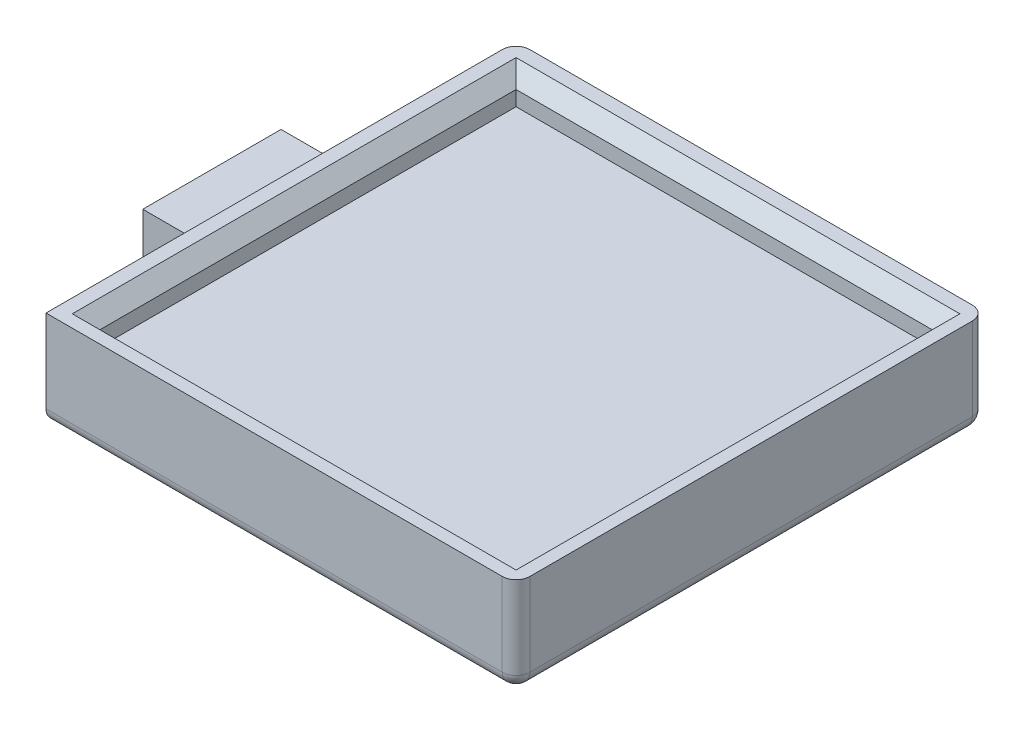
from build123d import *

# Parameters (mm, degrees)
EXTRUDE_1_DEPTH     = 5
SKETCH_2_W          = 34
SKETCH_2_H          = 34
EXTRUDE_2_DEPTH     = 2
SKETCH_3_W          = 30.1
SKETCH_3_H          = 30.1
CUT_EXTRUDE_2_DEPTH = 2.08
CHAMFER_1_SIZE      = 1
FILLET_2_R          = 1


with BuildPart() as part:
    # 草图1 → 凸台-拉伸1 (new body)
    with BuildSketch(Plane(origin=(0, 0, 0), x_dir=(1, 0, 0), z_dir=(0, 1, 0))):
        Polygon((0, 10), (5, 10), (5, 22), (39, 22), (39, -12), (5, -12), (5, 0), (0, 0), align=None)
    extrude(amount=EXTRUDE_1_DEPTH)

    # 草图2 → 凸台-拉伸2 (add)
    with BuildSketch(Plane(origin=(0, 5, 0), x_dir=(1, 0, 0), z_dir=(0, 1, 0))):
        with Locations((22, 5)):
            Rectangle(SKETCH_2_W, SKETCH_2_H)
    extrude(amount=EXTRUDE_2_DEPTH)

    # 草图3 → 切除-拉伸2 (cut)
    with BuildSketch(Plane(origin=(0, 7, 0), x_dir=(1, 0, 0), z_dir=(0, 1, 0))):
        with Locations((22.05, 4.95)):
            Rectangle(SKETCH_3_W, SKETCH_3_H)
    extrude(amount=-CUT_EXTRUDE_2_DEPTH, mode=Mode.SUBTRACT)

    # 倒角1
    chamfer_1_edges = [part.edges().sort_by_distance(p)[0] for p in [
        (22.05, 7, -20),
        (37.1, 7, -4.95),
        (22.05, 7, 10.1),
        (7, 7, -4.95),
    ]]
    chamfer(chamfer_1_edges, length=CHAMFER_1_SIZE)

    # 圆角2
    fillet_2_edges = [part.edges().sort_by_distance(p)[0] for p in [
        (39, 3.5, 12),
        (39, 3.5, -22),
        (5, 3.5, -22),
        (22, 0, 12),
        (39, 0, -5),
        (22, 0, -22),
    ]]
    fillet(fillet_2_edges, radius=FILLET_2_R)


solid = part.part
